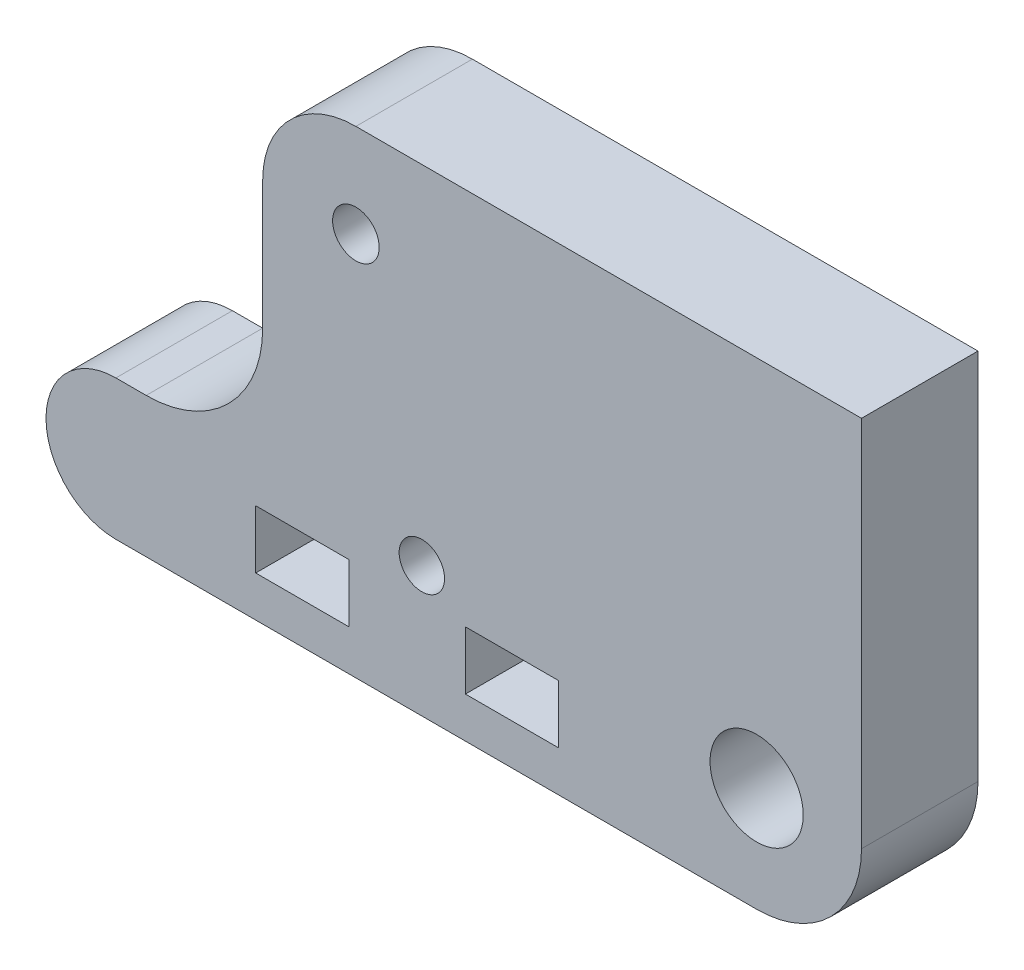
from build123d import *

# Parameters (mm, degrees)
SKETCH_1_W          = 8
SKETCH_1_H          = 5
SKETCH_1_R          = 1.949999999
SKETCH_1_R_2        = 4
SKETCH_1_R_3        = 2
BOSS_EXTRUDE1_DEPTH = 10


with BuildPart() as part:
    # Sketch 1 → Boss-Extrude1 (new body)
    with BuildSketch(Plane.XY):
        with BuildLine():
            ThreePointArc((27.5, 18), (33.863961031, 15.363961031), (36.5, 9))
            Line((36.5, 9), (36.5, 41))
            Line((36.5, 41), (-6.9, 41))
            ThreePointArc((-6.9, 41), (-1.243145751, 38.656854249), (1.1, 33))
            Line((1.1, 33), (1.1, 28))
            ThreePointArc((1.1, 28), (4.028932188, 20.928932188), (11.1, 18))
            Line((11.1, 18), (27.5, 18))
        make_face()
        with BuildLine():
            ThreePointArc((-27.5, 12), (-33.5, 6), (-27.5, 0))
            Line((-27.5, 0), (27.5, 0))
            ThreePointArc((27.5, 0), (33.863961031, 2.636038969), (36.5, 9))
            ThreePointArc((36.5, 9), (33.863961031, 15.363961031), (27.5, 18))
            Line((27.5, 18), (11.1, 18))
            ThreePointArc((11.1, 18), (4.028932188, 20.928932188), (1.1, 28))
            Line((1.1, 28), (1.1, 33))
            ThreePointArc((1.1, 33), (-1.243145751, 38.656854249), (-6.9, 41))
            ThreePointArc((-6.9, 41), (-12.556854249, 38.656854249), (-14.9, 33))
            Line((-14.9, 33), (-14.9, 22))
            ThreePointArc((-14.9, 22), (-17.828932188, 14.928932188), (-24.9, 12))
            Line((-24.9, 12), (-27.5, 12))
        make_face()
        with Locations((-11.5, 6)):
            Rectangle(SKETCH_1_W, SKETCH_1_H, mode=Mode.SUBTRACT)
        with Locations((-1.238171752, 11.18329463)):
            Circle(SKETCH_1_R, mode=Mode.SUBTRACT)
        with Locations((6.5, 6)):
            Rectangle(SKETCH_1_W, SKETCH_1_H, mode=Mode.SUBTRACT)
        with Locations((27.5, 9)):
            Circle(SKETCH_1_R_2, mode=Mode.SUBTRACT)
        with Locations((-6.9, 33)):
            Circle(SKETCH_1_R_3, mode=Mode.SUBTRACT)
    extrude(amount=BOSS_EXTRUDE1_DEPTH)


solid = part.part
